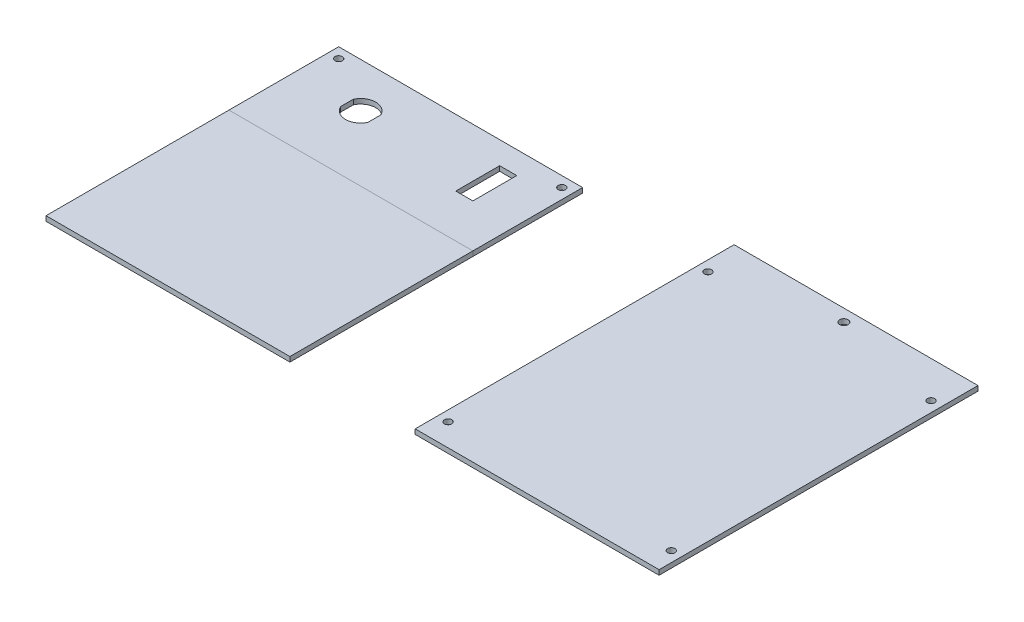
from build123d import *

# Parameters (mm, degrees)
SKETCH1_W             = 100
SKETCH1_H             = 45
SKETCH1_R             = 1.5
SKETCH1_W_2           = 7
SKETCH1_H_2           = 18
BOSS_EXTRUDE1_DEPTH   = 2
SKETCH1_H_3           = 130.75
SKETCH1_R_2           = 1.75
BOSS_EXTRUDE1_2_DEPTH = 2
SKETCH1_3_W           = 100
SKETCH1_3_H           = 75
BOSS_EXTRUDE2_DEPTH   = 2


with BuildPart() as part:
    # Sketch1 → Boss-Extrude1 (new body)
    with BuildSketch(Plane(origin=(0, 0, 0), x_dir=(1, 0, 0), z_dir=(0, 1, 0))):
        with Locations((50, 22.5)):
            Rectangle(SKETCH1_W, SKETCH1_H)
        with BuildLine():
            Line((21.643437278, 24.147957533), (21.643437278, 29.352042467))
            ThreePointArc((21.643437278, 29.352042467), (27.243437278, 32.925), (32.843437278, 29.352042467))
            Line((32.843437278, 29.352042467), (32.843437278, 24.147957533))
            ThreePointArc((32.843437278, 24.147957533), (27.243437278, 20.575), (21.643437278, 24.147957533))
        make_face(mode=Mode.SUBTRACT)
        with Locations((4.25, 40.75)):
            Circle(SKETCH1_R, mode=Mode.SUBTRACT)
        with Locations((78.75, 26.75)):
            Rectangle(SKETCH1_W_2, SKETCH1_H_2, mode=Mode.SUBTRACT)
        with Locations((95.75, 40.75)):
            Circle(SKETCH1_R, mode=Mode.SUBTRACT)
    extrude(amount=BOSS_EXTRUDE1_DEPTH)


with BuildPart() as body_2:
    # Sketch1 → Boss-Extrude1 2 (new body)
    with BuildSketch(Plane(origin=(0, 0, 0), x_dir=(1, 0, 0), z_dir=(0, 1, 0))):
        with Locations((201.354291092, -9.625)):
            Rectangle(SKETCH1_W, SKETCH1_H_3)
        with Locations((155.604291092, -65.75)):
            Circle(SKETCH1_R, mode=Mode.SUBTRACT)
        with Locations((247.104291092, -65.75)):
            Circle(SKETCH1_R, mode=Mode.SUBTRACT)
        with Locations((155.604291092, 40.75)):
            Circle(SKETCH1_R, mode=Mode.SUBTRACT)
        with Locations((201.354291092, 50.75)):
            Circle(SKETCH1_R_2, mode=Mode.SUBTRACT)
        with Locations((247.104291092, 40.75)):
            Circle(SKETCH1_R, mode=Mode.SUBTRACT)
    extrude(amount=BOSS_EXTRUDE1_2_DEPTH)


with BuildPart() as body_3:
    # Sketch1_3 → Boss-Extrude2 (new body)
    with BuildSketch(Plane(origin=(0, 0, 0), x_dir=(1, 0, 0), z_dir=(0, 1, 0))):
        with Locations((50, -37.5)):
            Rectangle(SKETCH1_3_W, SKETCH1_3_H)
    extrude(amount=BOSS_EXTRUDE2_DEPTH)


solid = Compound([part.part, body_2.part, body_3.part])
